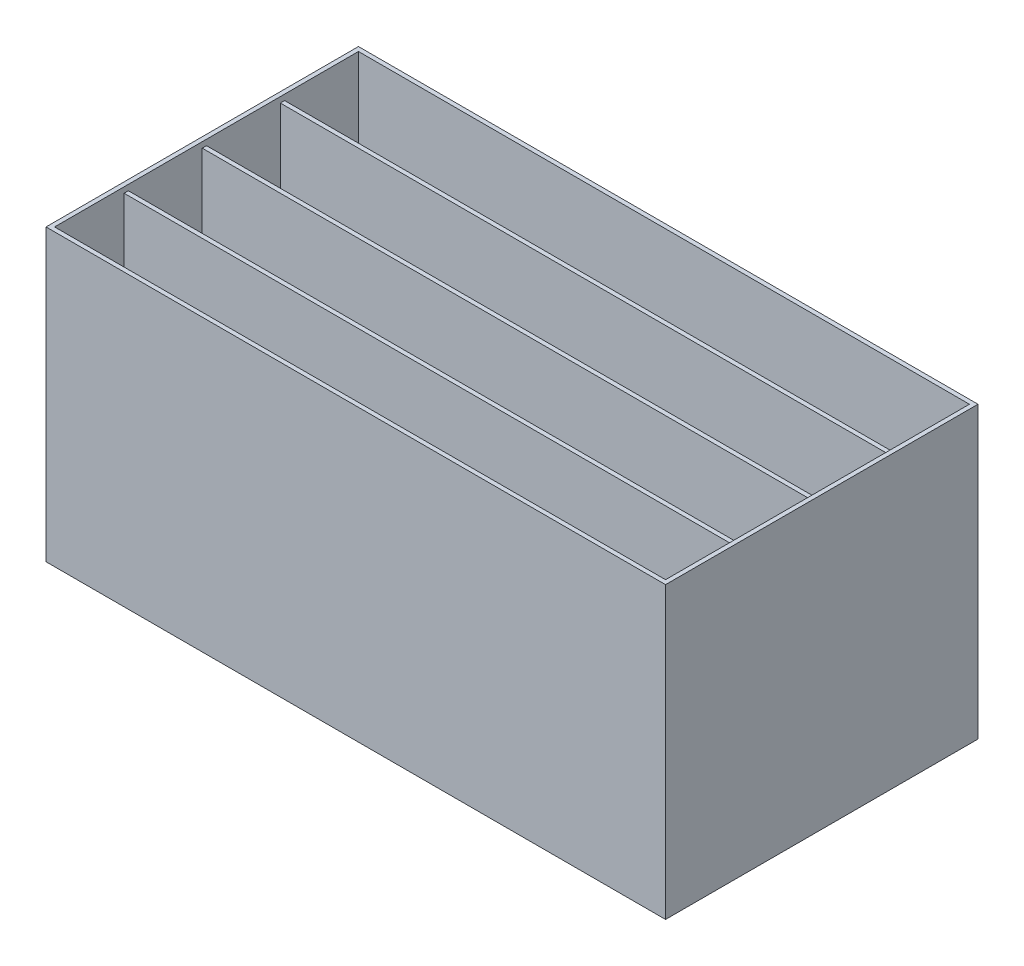
from build123d import *

# Parameters (mm, degrees)
SKETCH1_W                       = 919.1625
SKETCH1_H                       = 463.55
BOSS_EXTRUDE1_DEPTH             = 430.2125
SHELL1_T                        = -6.35
BOSS_EXTRUDE2_REACH             = 393.414
SKETCH2_W                       = 906.4625
SKETCH2_H                       = 6.35
BOSS_EXTRUDE2_DIRECTION_2_DEPTH = 30.48


with BuildPart() as part:
    # Sketch1 → Boss-Extrude1 (new body)
    with BuildSketch(Plane(origin=(0, 0, 0), x_dir=(1, 0, 0), z_dir=(0, 1, 0))):
        with Locations((459.58125, 231.775)):
            Rectangle(SKETCH1_W, SKETCH1_H)
    extrude(amount=BOSS_EXTRUDE1_DEPTH)

    # Shell1
    shell1_openings = [part.faces().sort_by_distance(p)[0] for p in [
        (459.58125, 430.2125, -231.775),
    ]]
    offset(amount=SHELL1_T, openings=shell1_openings, kind=Kind.INTERSECTION)

    # Sketch2 → Boss-Extrude2 (add, up to next)
    with BuildSketch(Plane(origin=(0, 391.414, 0), x_dir=(1, 0, 0), z_dir=(0, 1, 0)), mode=Mode.PRIVATE) as boss_extrude2_sk1:
        with Locations((459.58125, 344.4875)):
            Rectangle(SKETCH2_W, SKETCH2_H)
    boss_extrude2_tool1 = extrude(boss_extrude2_sk1.sketch, amount=-BOSS_EXTRUDE2_REACH, mode=Mode.PRIVATE) - part.part
    add(boss_extrude2_tool1.solids().sort_by_distance((459.58125, 391.414, -344.4875))[0])
    # Sketch2 → Boss-Extrude2 (add, up to next)
    with BuildSketch(Plane(origin=(0, 391.414, 0), x_dir=(1, 0, 0), z_dir=(0, 1, 0)), mode=Mode.PRIVATE) as boss_extrude2_sk2:
        with Locations((459.58125, 228.6)):
            Rectangle(SKETCH2_W, SKETCH2_H)
    boss_extrude2_tool2 = extrude(boss_extrude2_sk2.sketch, amount=-BOSS_EXTRUDE2_REACH, mode=Mode.PRIVATE) - part.part
    add(boss_extrude2_tool2.solids().sort_by_distance((459.58125, 391.414, -228.6))[0])
    # Sketch2 → Boss-Extrude2 (add, up to next)
    with BuildSketch(Plane(origin=(0, 391.414, 0), x_dir=(1, 0, 0), z_dir=(0, 1, 0)), mode=Mode.PRIVATE) as boss_extrude2_sk3:
        with Locations((459.58125, 112.7125)):
            Rectangle(SKETCH2_W, SKETCH2_H)
    boss_extrude2_tool3 = extrude(boss_extrude2_sk3.sketch, amount=-BOSS_EXTRUDE2_REACH, mode=Mode.PRIVATE) - part.part
    add(boss_extrude2_tool3.solids().sort_by_distance((459.58125, 391.414, -112.7125))[0])

    # Sketch2 → Boss-Extrude2 direction 2 (add)
    with BuildSketch(Plane(origin=(0, 391.414, 0), x_dir=(1, 0, 0), z_dir=(0, 1, 0))):
        with Locations((459.58125, 344.4875)):
            Rectangle(SKETCH2_W, SKETCH2_H)
        with Locations((459.58125, 228.6)):
            Rectangle(SKETCH2_W, SKETCH2_H)
        with Locations((459.58125, 112.7125)):
            Rectangle(SKETCH2_W, SKETCH2_H)
    extrude(amount=BOSS_EXTRUDE2_DIRECTION_2_DEPTH)


solid = part.part
